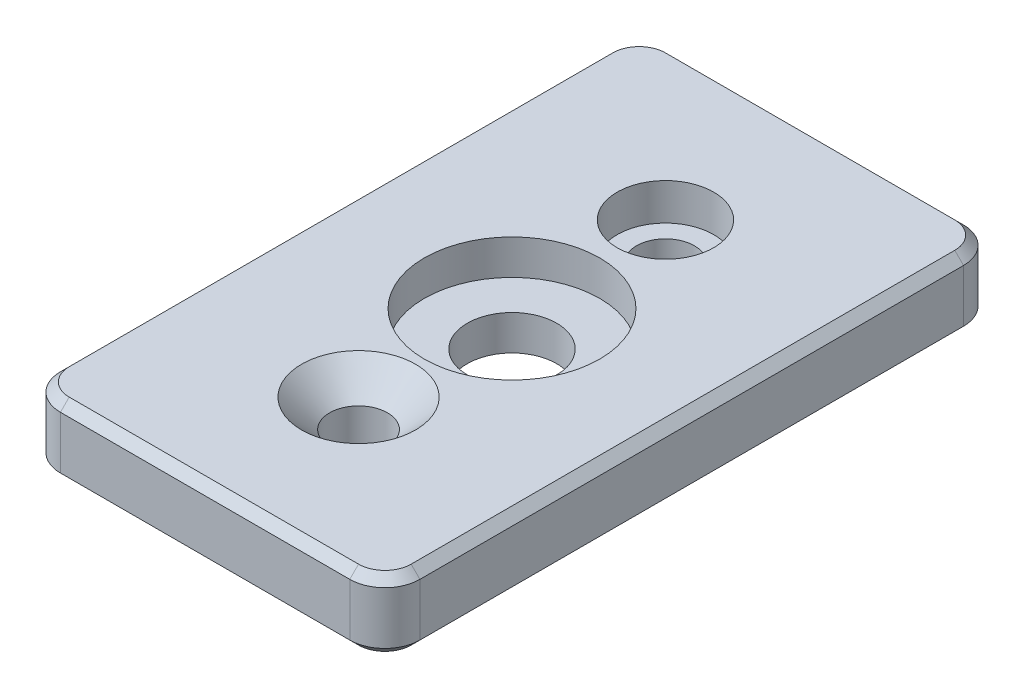
from build123d import *

# Parameters (mm, degrees)
SKETCH1_W           = 41
SKETCH1_H           = 70
BOSS_EXTRUDE1_DEPTH = 8
FILLET1_R           = 4
CHAMFER1_SIZE       = 1
SKETCH2_R           = 3.3
CUT_EXTRUDE1_DEPTH  = 8
CHAMFER2_SIZE       = 3.2
SKETCH3_R           = 5.5
CUT_EXTRUDE2_DEPTH  = 4.2
SKETCH4_R           = 5.1
CUT_EXTRUDE3_DEPTH  = 10
SKETCH5_R           = 10
CUT_EXTRUDE5_DEPTH  = 4


with BuildPart() as part:
    # Sketch1 → Boss-Extrude1 (new body)
    with BuildSketch(Plane(origin=(0, 0, 0), x_dir=(1, 0, 0), z_dir=(0, 1, 0))):
        Rectangle(SKETCH1_W, SKETCH1_H)
    extrude(amount=BOSS_EXTRUDE1_DEPTH)

    # Fillet1
    fillet1_edges = [part.edges().sort_by_distance(p)[0] for p in [
        (20.5, 4, 35),
        (-20.5, 4, 35),
        (-20.5, 4, -35),
        (20.5, 4, -35),
    ]]
    fillet(fillet1_edges, radius=FILLET1_R)

    # Chamfer1
    chamfer1_edges = [part.edges().sort_by_distance(p)[0] for p in [
        (-20.5, 0, 0),
        (-20.5, 8, 0),
        (20.5, 0, 0),
        (0, 0, 35),
        (0, 0, -35),
        (-19.328427125, 0, 33.828427125),
        (19.328427125, 0, 33.828427125),
        (19.328427125, 0, -33.828427125),
        (-19.328427125, 0, -33.828427125),
        (0, 8, -35),
        (20.5, 8, 0),
        (0, 8, 35),
        (-19.328427125, 8, 33.828427125),
        (19.328427125, 8, 33.828427125),
        (19.328427125, 8, -33.828427125),
        (-19.328427125, 8, -33.828427125),
    ]]
    chamfer(chamfer1_edges, length=CHAMFER1_SIZE)

    # Sketch2 → Cut-Extrude1 (cut)
    with BuildSketch(Plane(origin=(0, 8, 0), x_dir=(1, 0, 0), z_dir=(0, 1, 0))):
        with Locations((0, -17.5)):
            Circle(SKETCH2_R)
        with Locations((0, 17.5)):
            Circle(SKETCH2_R)
    extrude(amount=-CUT_EXTRUDE1_DEPTH, mode=Mode.SUBTRACT)

    # Chamfer2
    chamfer2_edges = [part.edges().sort_by_distance(p)[0] for p in [
        (-3.3, 8, 17.5),
    ]]
    chamfer(chamfer2_edges, length=CHAMFER2_SIZE)

    # Sketch3 → Cut-Extrude2 (cut)
    with BuildSketch(Plane(origin=(0, 8, 0), x_dir=(1, 0, 0), z_dir=(0, 1, 0))):
        with Locations((0, 17.5)):
            Circle(SKETCH3_R)
    extrude(amount=-CUT_EXTRUDE2_DEPTH, mode=Mode.SUBTRACT)

    # Sketch4 → Cut-Extrude3 (cut)
    with BuildSketch(Plane(origin=(0, 8, 0), x_dir=(1, 0, 0), z_dir=(0, 1, 0))):
        Circle(SKETCH4_R)
    extrude(amount=-CUT_EXTRUDE3_DEPTH, mode=Mode.SUBTRACT)

    # Sketch5 → Cut-Extrude5 (cut)
    with BuildSketch(Plane(origin=(0, 8, 0), x_dir=(1, 0, 0), z_dir=(0, 1, 0))):
        Circle(SKETCH5_R)
    extrude(amount=-CUT_EXTRUDE5_DEPTH, mode=Mode.SUBTRACT)


solid = part.part
